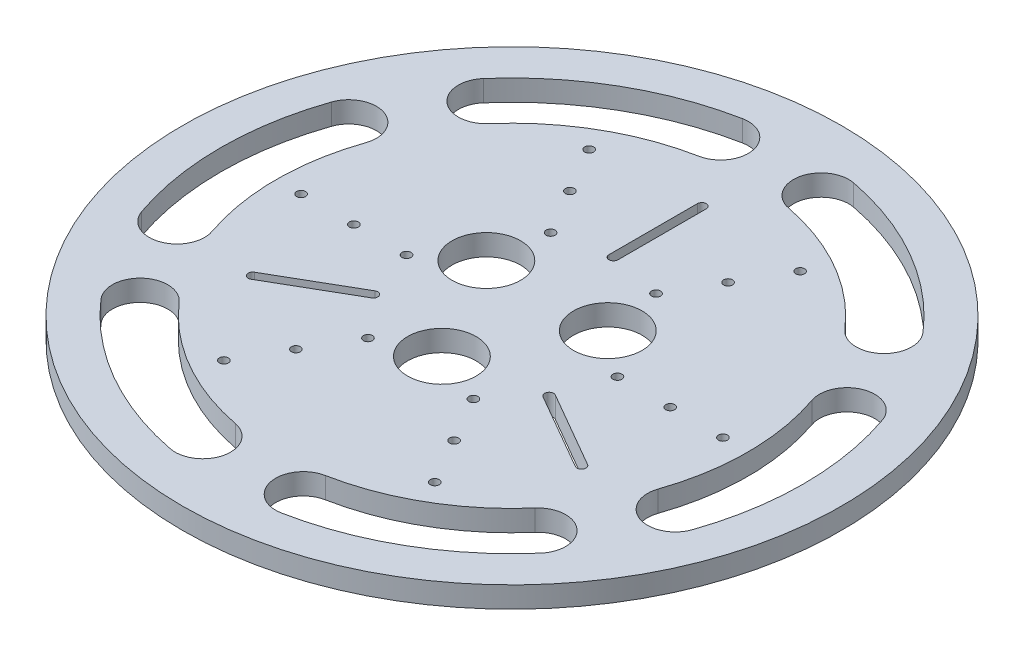
from build123d import *

# Parameters (mm, degrees)
BOSS_EXTRUDE4_START  = 175
SKETCH1_R            = 100
BOSS_EXTRUDE4_DEPTH  = 8
CUT_EXTRUDE5_DEPTH   = 10
SKETCH19_R           = 125
SKETCH19_R_2         = 100
BOSS_EXTRUDE11_DEPTH = 8
SKETCH20_R           = 1.7
CUT_EXTRUDE8_DEPTH   = 8
CUT_EXTRUDE9_START   = 183
SKETCH22_R           = 13
CUT_EXTRUDE9_DEPTH   = 8


with BuildPart() as part:
    # Sketch1 → Boss-Extrude4 (new body)
    with BuildSketch(Plane(origin=(0, 0, 0), x_dir=(1, 0, 0), z_dir=(0, 1, 0)).offset(BOSS_EXTRUDE4_START)):
        Circle(SKETCH1_R)
    extrude(amount=BOSS_EXTRUDE4_DEPTH)

    # Sketch15 → Cut-Extrude5 (cut)
    with BuildSketch(Plane(origin=(0, 183, 0), x_dir=(1, 0, 0), z_dir=(0, 1, 0))):
        with BuildLine():
            Line((1.7, 38.5), (1.7, 72))
            ThreePointArc((1.7, 72), (0, 73.7), (-1.7, 72))
            Line((-1.7, 72), (-1.7, 38.5))
            ThreePointArc((-1.7, 38.5), (0, 36.8), (1.7, 38.5))
        make_face()
        with BuildLine():
            Line((32.491978046, -20.722243186), (61.503829072, -37.472243186))
            ThreePointArc((61.503829072, -37.472243186), (63.826072259, -36.85), (63.203829072, -34.527756814))
            Line((63.203829072, -34.527756814), (34.191978046, -17.777756814))
            ThreePointArc((34.191978046, -17.777756814), (31.869734859, -18.4), (32.491978046, -20.722243186))
        make_face()
        with BuildLine():
            Line((-34.191978046, -17.777756814), (-63.203829072, -34.527756814))
            ThreePointArc((-63.203829072, -34.527756814), (-63.826072259, -36.85), (-61.503829072, -37.472243186))
            Line((-61.503829072, -37.472243186), (-32.491978046, -20.722243186))
            ThreePointArc((-32.491978046, -20.722243186), (-31.869734859, -18.4), (-34.191978046, -17.777756814))
        make_face()
    extrude(amount=-CUT_EXTRUDE5_DEPTH, mode=Mode.SUBTRACT)

    # Sketch19 → Boss-Extrude11 (add)
    with BuildSketch(Plane(origin=(0, 183, 0), x_dir=(1, 0, 0), z_dir=(0, 1, 0))):
        Circle(SKETCH19_R)
        Circle(SKETCH19_R_2, mode=Mode.SUBTRACT)
    extrude(amount=-BOSS_EXTRUDE11_DEPTH)

    # Sketch20 → Cut-Extrude8 (cut)
    with BuildSketch(Plane(origin=(0, 183, 0), x_dir=(1, 0, 0), z_dir=(0, 1, 0))):
        with Locations((30, -51.961524227)):
            Circle(SKETCH20_R)
        with Locations((40, -69.282032303)):
            Circle(SKETCH20_R)
        with Locations((20, -34.641016151)):
            Circle(SKETCH20_R)
        with Locations((-30, -51.961524227)):
            Circle(SKETCH20_R)
        with Locations((-40, -69.282032303)):
            Circle(SKETCH20_R)
        with Locations((-20, -34.641016151)):
            Circle(SKETCH20_R)
        with Locations((-60, 0)):
            Circle(SKETCH20_R)
        with Locations((-80, 0)):
            Circle(SKETCH20_R)
        with Locations((-40, 0)):
            Circle(SKETCH20_R)
        with Locations((-30, 51.961524227)):
            Circle(SKETCH20_R)
        with Locations((-40, 69.282032303)):
            Circle(SKETCH20_R)
        with Locations((-20, 34.641016151)):
            Circle(SKETCH20_R)
        with Locations((30, 51.961524227)):
            Circle(SKETCH20_R)
        with Locations((40, 69.282032303)):
            Circle(SKETCH20_R)
        with Locations((20, 34.641016151)):
            Circle(SKETCH20_R)
        with Locations((60, 0)):
            Circle(SKETCH20_R)
        with Locations((80, 0)):
            Circle(SKETCH20_R)
        with Locations((40, 0)):
            Circle(SKETCH20_R)
        with BuildLine():
            ThreePointArc((-21.032101141, 108.489004544), (-55.220471881, 95.723105208), (-83.386729073, 72.51804465))
            ThreePointArc((-83.386729073, 72.51804465), (-82.353167452, 57.69222173), (-67.527344531, 58.725783351))
            ThreePointArc((-67.527344531, 58.725783351), (-44.718048919, 77.517456037), (-17.031990051, 87.855399404))
            ThreePointArc((-17.031990051, 87.855399404), (-8.715243026, 100.172257519), (-21.032101141, 108.489004544))
        make_face()
        with BuildLine():
            ThreePointArc((83.438183396, 72.458836155), (55.288404899, 95.683884061), (21.109104364, 108.47404804))
            ThreePointArc((21.109104364, 108.47404804), (8.786345893, 100.16604596), (17.094347973, 87.84328749))
            ThreePointArc((17.094347973, 87.84328749), (44.773061705, 77.48569439), (67.569012718, 58.677835764))
            ThreePointArc((67.569012718, 58.677835764), (82.394098253, 57.633750621), (83.438183396, 72.458836155))
        make_face()
        with BuildLine():
            ThreePointArc((104.470284537, -36.030168389), (110.508876779, -0.039221146), (104.495833436, 35.95600339))
            ThreePointArc((104.495833436, 35.95600339), (91.139513345, 42.47382423), (84.621692504, 29.117504139))
            ThreePointArc((84.621692504, 29.117504139), (89.491110624, -0.031761647), (84.601002769, -29.177563641))
            ThreePointArc((84.601002769, -29.177563641), (91.109341279, -42.538506898), (104.470284537, -36.030168389))
        make_face()
        with BuildLine():
            ThreePointArc((21.032101141, -108.489004544), (55.220471881, -95.723105208), (83.386729073, -72.51804465))
            ThreePointArc((83.386729073, -72.51804465), (82.353167452, -57.69222173), (67.527344531, -58.725783351))
            ThreePointArc((67.527344531, -58.725783351), (44.718048919, -77.517456037), (17.031990051, -87.855399404))
            ThreePointArc((17.031990051, -87.855399404), (8.715243026, -100.172257519), (21.032101141, -108.489004544))
        make_face()
        with BuildLine():
            ThreePointArc((-83.438183396, -72.458836155), (-55.288404899, -95.683884061), (-21.109104364, -108.47404804))
            ThreePointArc((-21.109104364, -108.47404804), (-8.786345893, -100.16604596), (-17.094347973, -87.84328749))
            ThreePointArc((-17.094347973, -87.84328749), (-44.773061705, -77.48569439), (-67.569012718, -58.677835764))
            ThreePointArc((-67.569012718, -58.677835764), (-82.394098253, -57.633750621), (-83.438183396, -72.458836155))
        make_face()
        with BuildLine():
            ThreePointArc((-104.470284537, 36.030168389), (-110.508876779, 0.039221146), (-104.495833436, -35.95600339))
            ThreePointArc((-104.495833436, -35.95600339), (-91.139513345, -42.47382423), (-84.621692504, -29.117504139))
            ThreePointArc((-84.621692504, -29.117504139), (-89.491110624, 0.031761647), (-84.601002769, 29.177563641))
            ThreePointArc((-84.601002769, 29.177563641), (-91.109341279, 42.538506898), (-104.470284537, 36.030168389))
        make_face()
    extrude(amount=-CUT_EXTRUDE8_DEPTH, mode=Mode.SUBTRACT)

    # Sketch22 → Cut-Extrude9 (cut)
    with BuildSketch(Plane(origin=(0, 0, 0), x_dir=(1, 0, 0), z_dir=(0, 1, 0)).offset(CUT_EXTRUDE9_START)):
        with Locations((23.034671131, 13.299073578)):
            Circle(SKETCH22_R)
        with Locations((0, -26.598147157)):
            Circle(SKETCH22_R)
        with Locations((-23.034671131, 13.299073578)):
            Circle(SKETCH22_R)
    extrude(amount=-CUT_EXTRUDE9_DEPTH, mode=Mode.SUBTRACT)


solid = part.part
